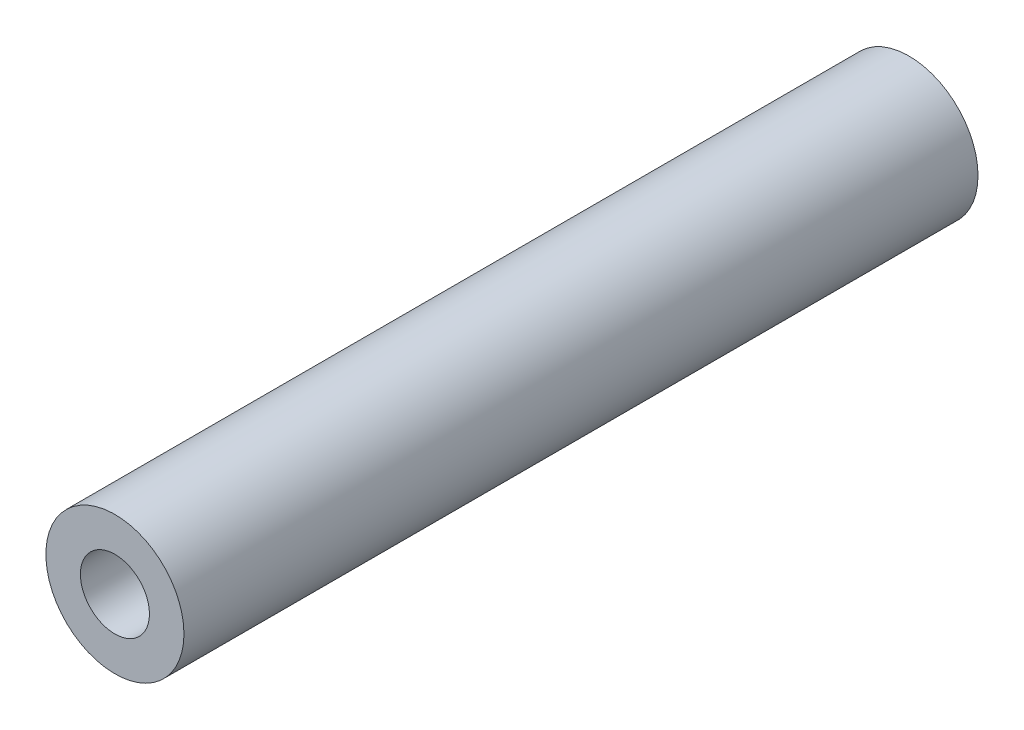
from build123d import *

# Parameters (mm, degrees)
ESQUISSE1_R      = 4
EXTRUSION2_DEPTH = 46
ESQUISSE2_R      = 2
EXTRUSION3_DEPTH = 10
ESQUISSE3_R      = 2
EXTRUSION4_DEPTH = 10


with BuildPart() as part:
    # Esquisse1 → Extrusion2 (new body)
    with BuildSketch(Plane.XY):
        Circle(ESQUISSE1_R)
    extrude(amount=EXTRUSION2_DEPTH)

    # Esquisse2 → Extrusion3 (cut)
    with BuildSketch(Plane.XY.offset(46)):
        Circle(ESQUISSE2_R)
    extrude(amount=-EXTRUSION3_DEPTH, mode=Mode.SUBTRACT)

    # Esquisse3 → Extrusion4 (cut)
    with BuildSketch(Plane(origin=(0, 0, 0), x_dir=(-1, 0, 0), z_dir=(0, 0, -1))):
        Circle(ESQUISSE3_R)
    extrude(amount=-EXTRUSION4_DEPTH, mode=Mode.SUBTRACT)


solid = part.part
